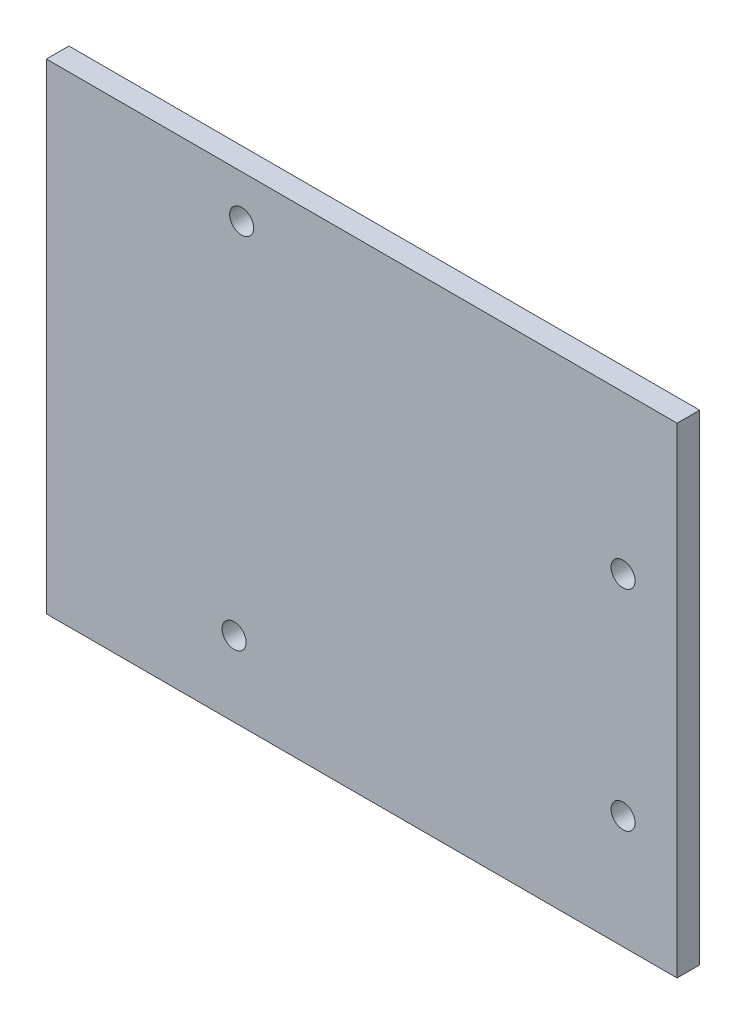
from build123d import *

# Parameters (mm, degrees)
SKETCH1_W           = 100
SKETCH1_H           = 100
BOSS_EXTRUDE1_DEPTH = 3
SKETCH2_R           = 1.6
CUT_EXTRUDE1_DEPTH  = 59
CUT_EXTRUDE2_DEPTH  = 3


with BuildPart() as part:
    # Sketch1 → Boss-Extrude1 (new body)
    with BuildSketch(Plane.XY):
        Rectangle(SKETCH1_W, SKETCH1_H)
    extrude(amount=BOSS_EXTRUDE1_DEPTH)

    # Sketch2 → Cut-Extrude1 (cut)
    with BuildSketch(Plane.XY.offset(3)):
        with Locations((26.807477417, -34.9)):
            Circle(SKETCH2_R)
        with Locations((26.807477417, -7)):
            Circle(SKETCH2_R)
        with Locations((-25, -40)):
            Circle(SKETCH2_R)
        with Locations((-23.992522583, 8.289491499)):
            Circle(SKETCH2_R)
    extrude(amount=-CUT_EXTRUDE1_DEPTH, mode=Mode.SUBTRACT)

    # Sketch3 → Cut-Extrude2 (cut)
    with BuildSketch(Plane.XY.offset(3)):
        Polygon((-50, 14), (34, 14), (34, -50), (50, -50), (50, 50), (-50, 50), align=None)
    extrude(amount=-CUT_EXTRUDE2_DEPTH, mode=Mode.SUBTRACT)


solid = part.part
